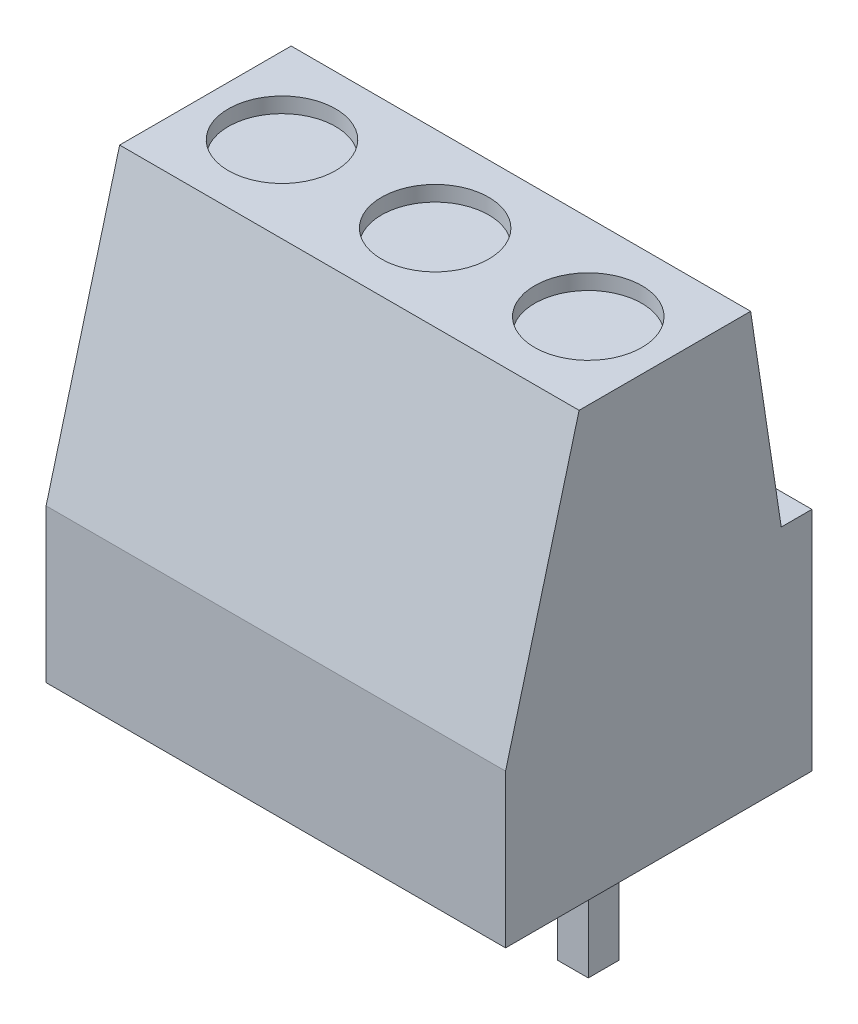
from build123d import *

# Parameters (mm, degrees)
SKETCH3_W           = 15
SKETCH3_H           = 10
BOSS_EXTRUDE3_DEPTH = 14
CUT_EXTRUDE1_DEPTH  = 22.118712082
SKETCH5_R           = 1.75
CUT_EXTRUDE2_DEPTH  = 0.5
SKETCH6_W           = 3
SKETCH6_H           = 3
CUT_EXTRUDE4_DEPTH  = 0.5
LPATTERN2_COUNT     = 3
LPATTERN2_PITCH     = 5
SKETCH7_W           = 1
SKETCH7_H           = 1
BOSS_EXTRUDE4_DEPTH = 4
LPATTERN3_COUNT     = 3
LPATTERN3_PITCH     = 5.08


with BuildPart() as part:
    # Sketch3 → Boss-Extrude3 (new body)
    with BuildSketch(Plane(origin=(0, 0, 0), x_dir=(1, 0, 0), z_dir=(0, 1, 0))):
        Rectangle(SKETCH3_W, SKETCH3_H)
    extrude(amount=BOSS_EXTRUDE3_DEPTH)

    # Sketch4 → Cut-Extrude1 (cut, through all)
    with BuildSketch(Plane.ZY.offset(7.5)):
        Polygon((-4, 7.4), (-3, 14), (-5, 14), (-5, 7.4), align=None)
        Polygon((5, 14), (2.6, 14), (5, 5), align=None)
    extrude(amount=-CUT_EXTRUDE1_DEPTH, mode=Mode.SUBTRACT)

    # Sketch5 → Cut-Extrude2 (cut)
    with BuildSketch(Plane(origin=(0, 14, 0), x_dir=(1, 0, 0), z_dir=(0, 1, 0))):
        with Locations((-5, 0.2)):
            Circle(SKETCH5_R)
    cut_extrude2 = extrude(amount=-CUT_EXTRUDE2_DEPTH, mode=Mode.SUBTRACT)

    # Sketch6 → Cut-Extrude4 (cut)
    with BuildSketch(Plane(origin=(0, 0, -5), x_dir=(-1, 0, 0), z_dir=(0, 0, -1))):
        with Locations((5, 2.9)):
            Rectangle(SKETCH6_W, SKETCH6_H)
    cut_extrude4 = extrude(amount=-CUT_EXTRUDE4_DEPTH, mode=Mode.SUBTRACT)

    # LPattern2: Cut-Extrude2, Cut-Extrude4 ×3
    with Locations(*[(i * LPATTERN2_PITCH, 0, 0) for i in range(1, LPATTERN2_COUNT)]):
        add(cut_extrude2, mode=Mode.SUBTRACT)
        add(cut_extrude4, mode=Mode.SUBTRACT)


with BuildPart() as body_2:
    # Sketch7 → Boss-Extrude4 (new body)
    with BuildSketch(Plane.XZ):
        with Locations((-4.96, 0)):
            Rectangle(SKETCH7_W, SKETCH7_H)
    boss_extrude4 = extrude(amount=BOSS_EXTRUDE4_DEPTH)


with BuildPart() as lpattern3_1:
    # LPattern3: Boss-Extrude4 ×3
    with Locations(*[(i * LPATTERN3_PITCH, 0, 0) for i in range(1, LPATTERN3_COUNT)]):
        add(boss_extrude4)


solid = Compound([part.part, body_2.part, lpattern3_1.part])
